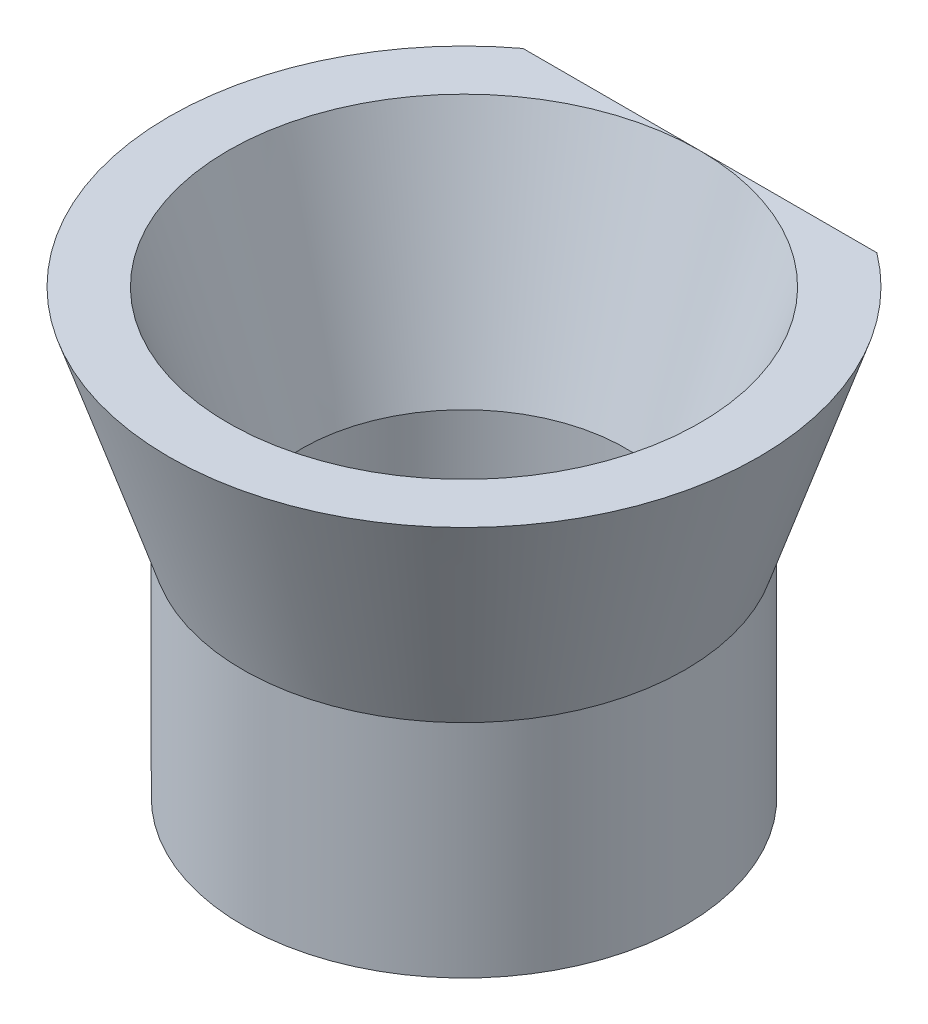
from build123d import *

# Parameters (mm, degrees)
CROQUIS3_R              = 7.5
CROQUIS3_R_2            = 5.5
SALIENTE_EXTRUIR1_DEPTH = 7.5
CROQUIS4_W              = 14.601596012
CROQUIS4_H              = 2.867230366
CORTAR_EXTRUIR1_DEPTH   = 19.5


with BuildPart() as part:
    # Croquis2 → Revolución1 (revolve)
    with BuildSketch(Plane.XY):
        Polygon((-5.5, 0), (-8, 7.5), (-10, 7.5), (-7.5, 0), align=None)
    revolve(axis=Axis((0, 7.5, 0), (0, -1, 0)))

    # Croquis3 → Saliente-Extruir1 (add)
    with BuildSketch(Plane.XZ):
        Circle(CROQUIS3_R)
        Circle(CROQUIS3_R_2, mode=Mode.SUBTRACT)
    extrude(amount=SALIENTE_EXTRUIR1_DEPTH)

    # Croquis4 → Cortar-Extruir1 (cut)
    with BuildSketch(Plane(origin=(0, 7.5, 0), x_dir=(1, 0, 0), z_dir=(0, 1, 0))):
        with Locations((0, 9.433615183)):
            Rectangle(CROQUIS4_W, CROQUIS4_H)
    extrude(amount=-CORTAR_EXTRUIR1_DEPTH, mode=Mode.SUBTRACT)


solid = part.part
